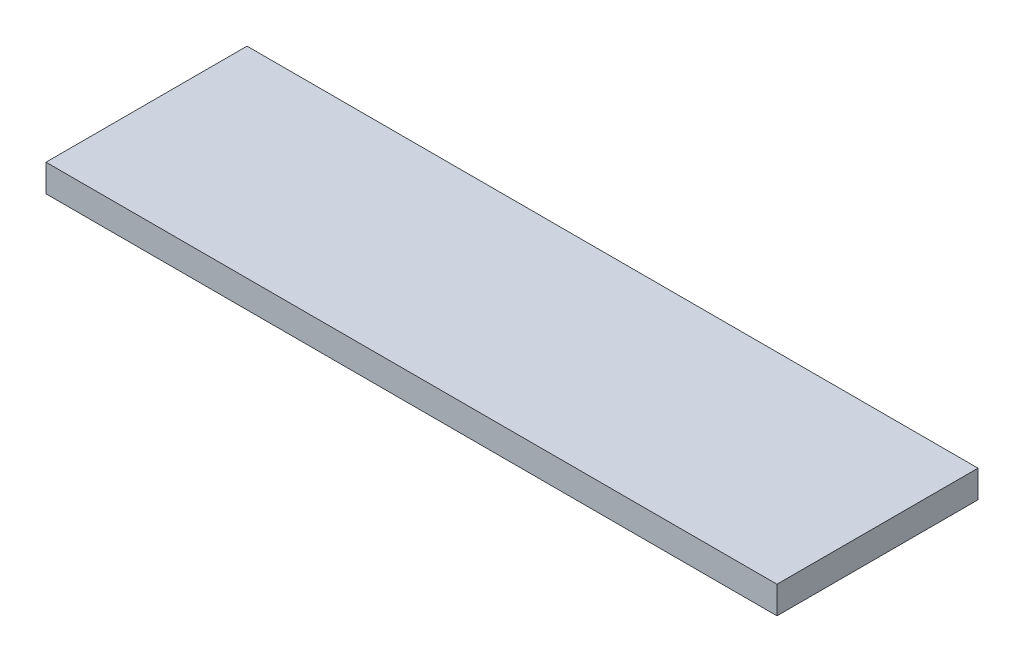
from build123d import *

# Parameters (mm, degrees)
SKETCH2_W           = 1016
SKETCH2_H           = 279.4
BOSS_EXTRUDE1_DEPTH = 38.1


with BuildPart() as part:
    # Sketch2 → Boss-Extrude1 (new body)
    with BuildSketch(Plane(origin=(0, 0, 0), x_dir=(1, 0, 0), z_dir=(0, 1, 0))):
        Rectangle(SKETCH2_W, SKETCH2_H)
    extrude(amount=BOSS_EXTRUDE1_DEPTH)


solid = part.part
